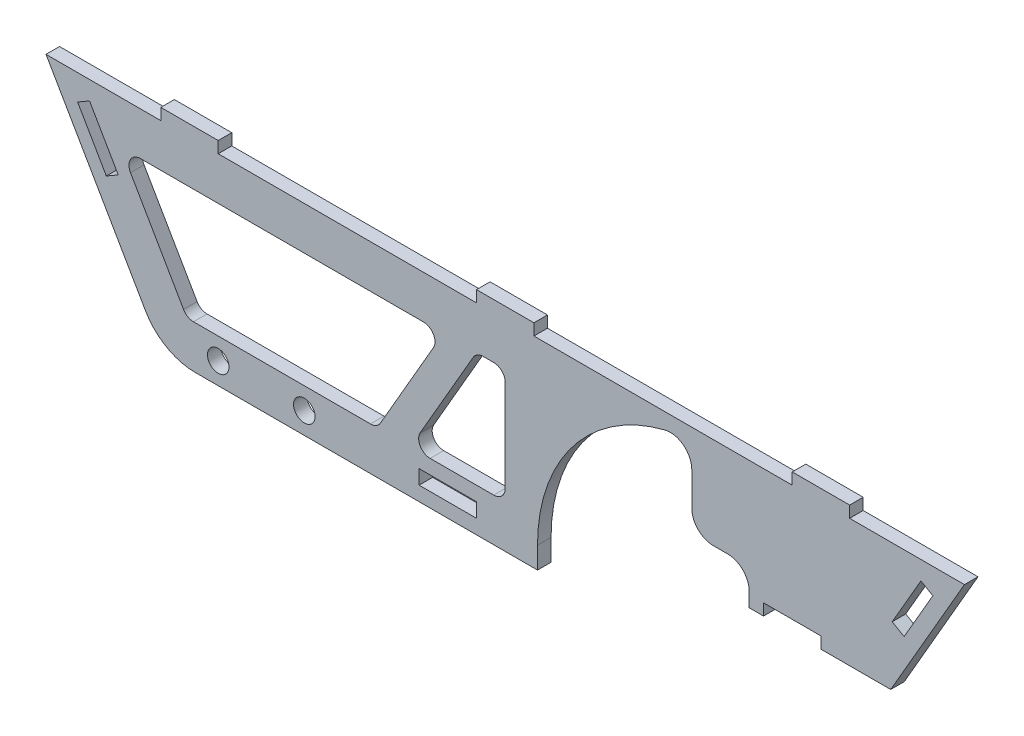
from build123d import *

# Parameters (mm, degrees)
EXTRUDE1_DEPTH        = 2.9972
SKETCH2_W             = 12.7
SKETCH2_H             = 2.54
TABS_DEPTH            = 2.9972
SKETCH3_W             = 12.7
SKETCH3_H             = 3.175
SKETCH3_H_2           = 2.54
SLOTS_DEPTH           = 3.9972
SKETCH4_R             = 2.38125
HOLES_DEPTH           = 3.9972
WHEEL_CLEARANCE_DEPTH = 3.9972
FILLET1_R             = 2.54
FILLET2_R             = 4.7625
FILLET3_R             = 12.7


with BuildPart() as part:
    # Sketch1 → Extrude1 (new body)
    with BuildSketch(Plane.XY):
        Polygon((101.6, 22.225), (-101.6, 22.225), (-75.936780535, -22.225), (75.936780535, -22.225), align=None)
        Polygon((-85.102216058, 12.7), (-13.682348419, 12.7), (-28.347045256, -12.7), (-70.43751922, -12.7), align=None, mode=Mode.SUBTRACT)
        Polygon((-6.35, 12.7), (0, 12.7), (0, -12.7), (-21.014696837, -12.7), align=None, mode=Mode.SUBTRACT)
    extrude(amount=EXTRUDE1_DEPTH)

    # Sketch2 → Tabs (add, through all)
    with BuildSketch(Plane.XY.offset(2.9972)):
        with Locations((-69.85, 23.495)):
            Rectangle(SKETCH2_W, SKETCH2_H)
        with Locations((69.85, 23.495)):
            Rectangle(SKETCH2_W, SKETCH2_H)
        with Locations((0, 23.495)):
            Rectangle(SKETCH2_W, SKETCH2_H)
    extrude(amount=-TABS_DEPTH)

    # Sketch3 → Slots (cut, through all)
    with BuildSketch(Plane.XY.offset(2.9972)):
        Polygon((-94.605125878, 16.586522628), (-88.255125878, 5.588), (-85.615480447, 7.112), (-91.965480447, 18.110522628), align=None)
        with Locations((-12.7, -17.4625)):
            Rectangle(SKETCH3_W, SKETCH3_H)
        Polygon((91.965480447, 18.110522628), (85.615480447, 7.112), (88.255125878, 5.588), (94.605125878, 16.586522628), align=None)
        with Locations((63.5, -4.7625)):
            Rectangle(SKETCH3_W, SKETCH3_H_2)
    extrude(amount=-SLOTS_DEPTH, mode=Mode.SUBTRACT)

    # Sketch4 → Holes (cut, through all)
    with BuildSketch(Plane.XY.offset(2.9972)):
        with Locations((-63.5, -17.4625)):
            Circle(SKETCH4_R)
        with Locations((-44.45, -17.4625)):
            Circle(SKETCH4_R)
    extrude(amount=-HOLES_DEPTH, mode=Mode.SUBTRACT)

    # Sketch5 → Wheel Clearance (cut, through all)
    with BuildSketch(Plane.XY.offset(2.9972)):
        with BuildLine():
            Line((41.275, 19.70839808), (41.275, 1.905))
            Line((41.275, 1.905), (53.975, 1.905))
            Line((53.975, 1.905), (53.975, -6.0325))
            Line((53.975, -6.0325), (85.285524768, -6.0325))
            Line((85.285524768, -6.0325), (85.285524768, -22.225))
            Line((85.285524768, -22.225), (29.36875, -22.225))
            Line((29.36875, -22.225), (7.14375, -22.225))
            Line((7.14375, -22.225), (7.14375, -17.4625))
            ThreePointArc((7.14375, -17.4625), (16.970883995, 7.769512854), (41.275, 19.70839808))
        make_face()
    extrude(amount=-WHEEL_CLEARANCE_DEPTH, mode=Mode.SUBTRACT)

    # Fillet1
    fillet1_edges = [part.edges().sort_by_distance(p)[0] for p in [
        (-21.014696837, -12.7, 1.4986),
        (0, -12.7, 1.4986),
        (0, 12.7, 1.4986),
        (-6.35, 12.7, 1.4986),
        (-28.347045256, -12.7, 1.4986),
        (-13.682348419, 12.7, 1.4986),
        (-85.102216058, 12.7, 1.4986),
        (-70.43751922, -12.7, 1.4986),
    ]]
    fillet(fillet1_edges, radius=FILLET1_R)

    # Fillet2
    fillet2_edges = [part.edges().sort_by_distance(p)[0] for p in [
        (41.275, 19.70839808, 1.4986),
        (41.275, 1.905, 1.4986),
        (53.975, 1.905, 1.4986),
    ]]
    fillet(fillet2_edges, radius=FILLET2_R)

    # Fillet3
    fillet3_edges = [part.edges().sort_by_distance(p)[0] for p in [
        (-75.936780535, -22.225, 1.4986),
    ]]
    fillet(fillet3_edges, radius=FILLET3_R)


solid = part.part
